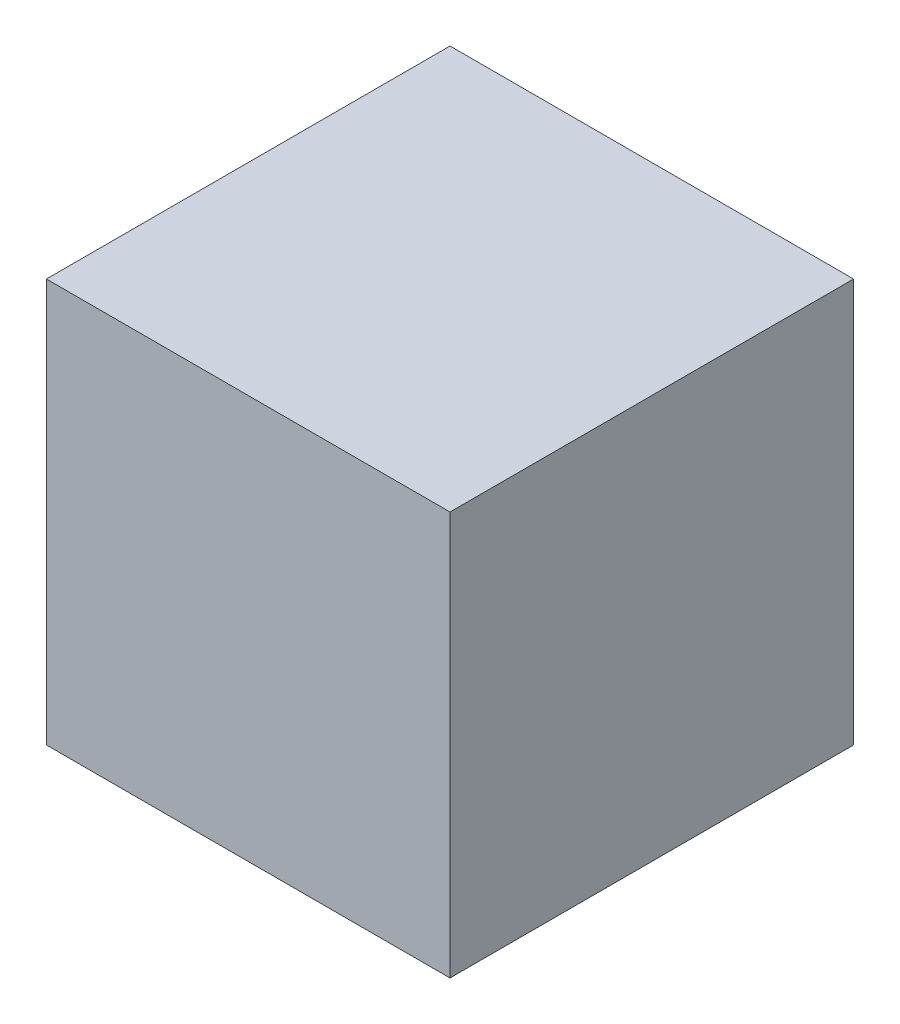
from build123d import *

# Parameters (mm, degrees)
SKETCH1_W                 = 10
SKETCH1_H                 = 10
BOSS_EXTRUDE1_DEPTH       = 5
M3X0_5_TAPPED_HOLE1_D     = 2.5
M3X0_5_TAPPED_HOLE1_DEPTH = 6.748924226
M3X0_5_TAPPED_HOLE1_TIP   = 0.751075774


with BuildPart() as part:
    # Sketch1 → Boss-Extrude1 (new body, symmetric)
    with BuildSketch(Plane.XY):
        Rectangle(SKETCH1_W, SKETCH1_H)
    extrude(amount=BOSS_EXTRUDE1_DEPTH, both=True)

    # M3x0.5 Tapped Hole1
    with Locations(Plane(origin=(0, -5, 0), x_dir=(-1, 0, 0), z_dir=(0, -1, 0))):
        with Locations((-2.5, 0), (2.5, 0)):
            Hole(M3X0_5_TAPPED_HOLE1_D / 2, depth=M3X0_5_TAPPED_HOLE1_DEPTH)
            with Locations((0, 0, -(M3X0_5_TAPPED_HOLE1_DEPTH + M3X0_5_TAPPED_HOLE1_TIP / 2))):  # 118° drill point
                Cone(0, M3X0_5_TAPPED_HOLE1_D / 2, M3X0_5_TAPPED_HOLE1_TIP, mode=Mode.SUBTRACT)


solid = part.part
